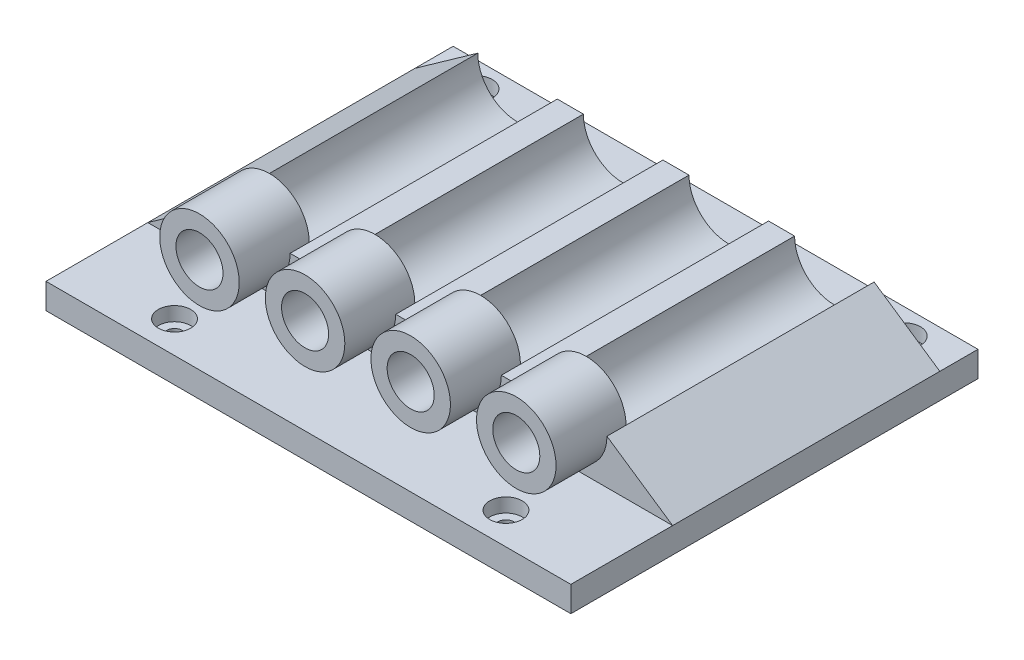
from build123d import *

# Parameters (mm, degrees)
SKETCH1_W                  = 104.775
SKETCH1_H                  = 81.28
BOSS_EXTRUDE1_DEPTH        = 2.54
CUT_EXTRUDE1_REACH         = 7.08
SKETCH2_R                  = 1.5875
BOSS_EXTRUDE7_DEPTH        = 20.32
BOSS_EXTRUDE7_DEPTH_BACK   = 33.02
SKETCH8_R                  = 7.9375
BOSS_EXTRUDE8_DEPTH        = 10.16
BOSS_EXTRUDE8_DEPTH_BACK   = 3.81
BOSS_EXTRUDE8_2_DEPTH      = 10.16
BOSS_EXTRUDE8_2_DEPTH_BACK = 3.81
BOSS_EXTRUDE8_3_DEPTH      = 10.16
BOSS_EXTRUDE8_3_DEPTH_BACK = 3.81
BOSS_EXTRUDE8_4_DEPTH      = 10.16
BOSS_EXTRUDE8_4_DEPTH_BACK = 3.81
SKETCH11_R                 = 3.2385
CUT_EXTRUDE4_DEPTH         = 2.794
SKETCH9_R                  = 1.27
CUT_EXTRUDE2_DEPTH         = 13.97
SKETCH10_R                 = 4.699
SKETCH10_R_2               = 1.27
CUT_EXTRUDE3_DEPTH         = 10.795


with BuildPart() as part:
    # Sketch1 → Boss-Extrude1 (new body, symmetric)
    with BuildSketch(Plane(origin=(0, 0, 0), x_dir=(1, 0, 0), z_dir=(0, 1, 0))):
        Rectangle(SKETCH1_W, SKETCH1_H)
    extrude(amount=BOSS_EXTRUDE1_DEPTH, both=True)

    # Sketch2 → Cut-Extrude1 (cut, up to next)
    with BuildSketch(Plane(origin=(0, 2.54, 0), x_dir=(1, 0, 0), z_dir=(0, 1, 0)), mode=Mode.PRIVATE) as cut_extrude1_sk1:
        with Locations((-33.0835, -34.29)):
            Circle(SKETCH2_R)
    cut_extrude1_tool1 = extrude(cut_extrude1_sk1.sketch, amount=-CUT_EXTRUDE1_REACH, mode=Mode.PRIVATE) & part.part
    add(cut_extrude1_tool1.solids().sort_by_distance((-33.0835, 2.54, 34.29))[0], mode=Mode.SUBTRACT)
    # Sketch2 → Cut-Extrude1 (cut, up to next)
    with BuildSketch(Plane(origin=(0, 2.54, 0), x_dir=(1, 0, 0), z_dir=(0, 1, 0)), mode=Mode.PRIVATE) as cut_extrude1_sk2:
        with Locations((33.0835, -34.29)):
            Circle(SKETCH2_R)
    cut_extrude1_tool2 = extrude(cut_extrude1_sk2.sketch, amount=-CUT_EXTRUDE1_REACH, mode=Mode.PRIVATE) & part.part
    add(cut_extrude1_tool2.solids().sort_by_distance((33.0835, 2.54, 34.29))[0], mode=Mode.SUBTRACT)
    # Sketch2 → Cut-Extrude1 (cut, up to next)
    with BuildSketch(Plane(origin=(0, 2.54, 0), x_dir=(1, 0, 0), z_dir=(0, 1, 0)), mode=Mode.PRIVATE) as cut_extrude1_sk3:
        with Locations((42.7355, 35.56)):
            Circle(SKETCH2_R)
    cut_extrude1_tool3 = extrude(cut_extrude1_sk3.sketch, amount=-CUT_EXTRUDE1_REACH, mode=Mode.PRIVATE) & part.part
    add(cut_extrude1_tool3.solids().sort_by_distance((42.7355, 2.54, -35.56))[0], mode=Mode.SUBTRACT)
    # Sketch2 → Cut-Extrude1 (cut, up to next)
    with BuildSketch(Plane(origin=(0, 2.54, 0), x_dir=(1, 0, 0), z_dir=(0, 1, 0)), mode=Mode.PRIVATE) as cut_extrude1_sk4:
        with Locations((-42.7355, 35.56)):
            Circle(SKETCH2_R)
    cut_extrude1_tool4 = extrude(cut_extrude1_sk4.sketch, amount=-CUT_EXTRUDE1_REACH, mode=Mode.PRIVATE) & part.part
    add(cut_extrude1_tool4.solids().sort_by_distance((-42.7355, 2.54, -35.56))[0], mode=Mode.SUBTRACT)

    # Sketch7 → Boss-Extrude7 (add, two sides)
    with BuildSketch(Plane.XY) as boss_extrude7_sk:
        with BuildLine():
            Line((-23.974123011, 11.43), (-18.767123011, 11.43))
            ThreePointArc((-18.767123011, 11.43), (-10.829623011, 3.4925), (-2.892123011, 11.43))
            Line((-2.892123011, 11.43), (2.314876989, 11.43))
            ThreePointArc((2.314876989, 11.43), (10.252376989, 3.4925), (18.189876989, 11.43))
            Line((18.189876989, 11.43), (23.396876989, 11.43))
            ThreePointArc((23.396876989, 11.43), (31.334376989, 3.4925), (39.271876989, 11.43))
            Line((39.271876989, 11.43), (52.3875, 2.54))
            Line((52.3875, 2.54), (-52.3875, 2.54))
            Line((-52.3875, 2.54), (-39.849123011, 11.43))
            ThreePointArc((-39.849123011, 11.43), (-31.911623011, 3.4925), (-23.974123011, 11.43))
        make_face()
    extrude(amount=BOSS_EXTRUDE7_DEPTH)
    extrude(boss_extrude7_sk.sketch, amount=-BOSS_EXTRUDE7_DEPTH_BACK)

    # Sketch11 → Cut-Extrude4 (cut)
    with BuildSketch(Plane(origin=(0, 2.54, 0), x_dir=(1, 0, 0), z_dir=(0, 1, 0))):
        with Locations((-33.0835, -34.29)):
            Circle(SKETCH11_R)
        with Locations((33.0835, -34.29)):
            Circle(SKETCH11_R)
        with Locations((42.7355, 35.56)):
            Circle(SKETCH11_R)
        with Locations((-42.7355, 35.56)):
            Circle(SKETCH11_R)
    extrude(amount=-CUT_EXTRUDE4_DEPTH, mode=Mode.SUBTRACT)


with BuildPart() as body_2:
    # Sketch8 → Boss-Extrude8 (new body, two sides)
    with BuildSketch(Plane.XY.offset(20.32)) as boss_extrude8_sk:
        with Locations((-31.911623011, 11.43)):
            Circle(SKETCH8_R)
    extrude(amount=BOSS_EXTRUDE8_DEPTH)
    extrude(boss_extrude8_sk.sketch, amount=-BOSS_EXTRUDE8_DEPTH_BACK)


with BuildPart() as body_3:
    # Sketch8 → Boss-Extrude8 2 (new body, two sides)
    with BuildSketch(Plane.XY.offset(20.32)) as boss_extrude8_2_sk:
        with Locations((-10.829623011, 11.43)):
            Circle(SKETCH8_R)
    extrude(amount=BOSS_EXTRUDE8_2_DEPTH)
    extrude(boss_extrude8_2_sk.sketch, amount=-BOSS_EXTRUDE8_2_DEPTH_BACK)


with BuildPart() as body_4:
    # Sketch8 → Boss-Extrude8 3 (new body, two sides)
    with BuildSketch(Plane.XY.offset(20.32)) as boss_extrude8_3_sk:
        with Locations((10.252376989, 11.43)):
            Circle(SKETCH8_R)
    extrude(amount=BOSS_EXTRUDE8_3_DEPTH)
    extrude(boss_extrude8_3_sk.sketch, amount=-BOSS_EXTRUDE8_3_DEPTH_BACK)


with BuildPart() as body_5:
    # Sketch8 → Boss-Extrude8 4 (new body, two sides)
    with BuildSketch(Plane.XY.offset(20.32)) as boss_extrude8_4_sk:
        with Locations((31.334376989, 11.43)):
            Circle(SKETCH8_R)
    extrude(amount=BOSS_EXTRUDE8_4_DEPTH)
    extrude(boss_extrude8_4_sk.sketch, amount=-BOSS_EXTRUDE8_4_DEPTH_BACK)


with BuildPart() as cut_extrude2_tool:
    # Sketch9 → Cut-Extrude2 (new body)
    with BuildSketch(Plane(origin=(0, 0, 16.51), x_dir=(-1, 0, 0), z_dir=(0, 0, -1))):
        with Locations((-31.334376989, 11.43)):
            Circle(SKETCH9_R)
        with Locations((-10.252376989, 11.43)):
            Circle(SKETCH9_R)
        with Locations((10.829623011, 11.43)):
            Circle(SKETCH9_R)
        with Locations((31.911623011, 11.43)):
            Circle(SKETCH9_R)
    extrude(amount=-CUT_EXTRUDE2_DEPTH)


with BuildPart() as body_2_1:
    add(body_2.part)

    # Cut-Extrude2: cut by cut_extrude2_tool
    add(cut_extrude2_tool.part, mode=Mode.SUBTRACT)


with BuildPart() as body_3_1:
    add(body_3.part)

    # Cut-Extrude2: cut by cut_extrude2_tool
    add(cut_extrude2_tool.part, mode=Mode.SUBTRACT)


with BuildPart() as body_4_1:
    add(body_4.part)

    # Cut-Extrude2: cut by cut_extrude2_tool
    add(cut_extrude2_tool.part, mode=Mode.SUBTRACT)


with BuildPart() as body_5_1:
    add(body_5.part)

    # Cut-Extrude2: cut by cut_extrude2_tool
    add(cut_extrude2_tool.part, mode=Mode.SUBTRACT)


with BuildPart() as cut_extrude3_tool:
    # Sketch10 → Cut-Extrude3 (new body)
    with BuildSketch(Plane.XY.offset(30.48)):
        with Locations((-31.911623011, 11.43)):
            Circle(SKETCH10_R)
        with Locations((-31.911623011, 11.43)):
            Circle(SKETCH10_R_2, mode=Mode.SUBTRACT)
        with Locations((-10.829623011, 11.43)):
            Circle(SKETCH10_R)
        with Locations((-10.829623011, 11.43)):
            Circle(SKETCH10_R_2, mode=Mode.SUBTRACT)
        with Locations((10.252376989, 11.43)):
            Circle(SKETCH10_R)
        with Locations((10.252376989, 11.43)):
            Circle(SKETCH10_R_2, mode=Mode.SUBTRACT)
        with Locations((31.334376989, 11.43)):
            Circle(SKETCH10_R)
        with Locations((31.334376989, 11.43)):
            Circle(SKETCH10_R_2, mode=Mode.SUBTRACT)
    extrude(amount=-CUT_EXTRUDE3_DEPTH)


with BuildPart() as body_2_2:
    add(body_2_1.part)

    # Cut-Extrude3: cut by cut_extrude3_tool
    add(cut_extrude3_tool.part, mode=Mode.SUBTRACT)


with BuildPart() as body_3_2:
    add(body_3_1.part)

    # Cut-Extrude3: cut by cut_extrude3_tool
    add(cut_extrude3_tool.part, mode=Mode.SUBTRACT)


with BuildPart() as body_4_2:
    add(body_4_1.part)

    # Cut-Extrude3: cut by cut_extrude3_tool
    add(cut_extrude3_tool.part, mode=Mode.SUBTRACT)


with BuildPart() as body_5_2:
    add(body_5_1.part)

    # Cut-Extrude3: cut by cut_extrude3_tool
    add(cut_extrude3_tool.part, mode=Mode.SUBTRACT)


solid = Compound([part.part, body_2_2.part, body_3_2.part, body_4_2.part, body_5_2.part])
